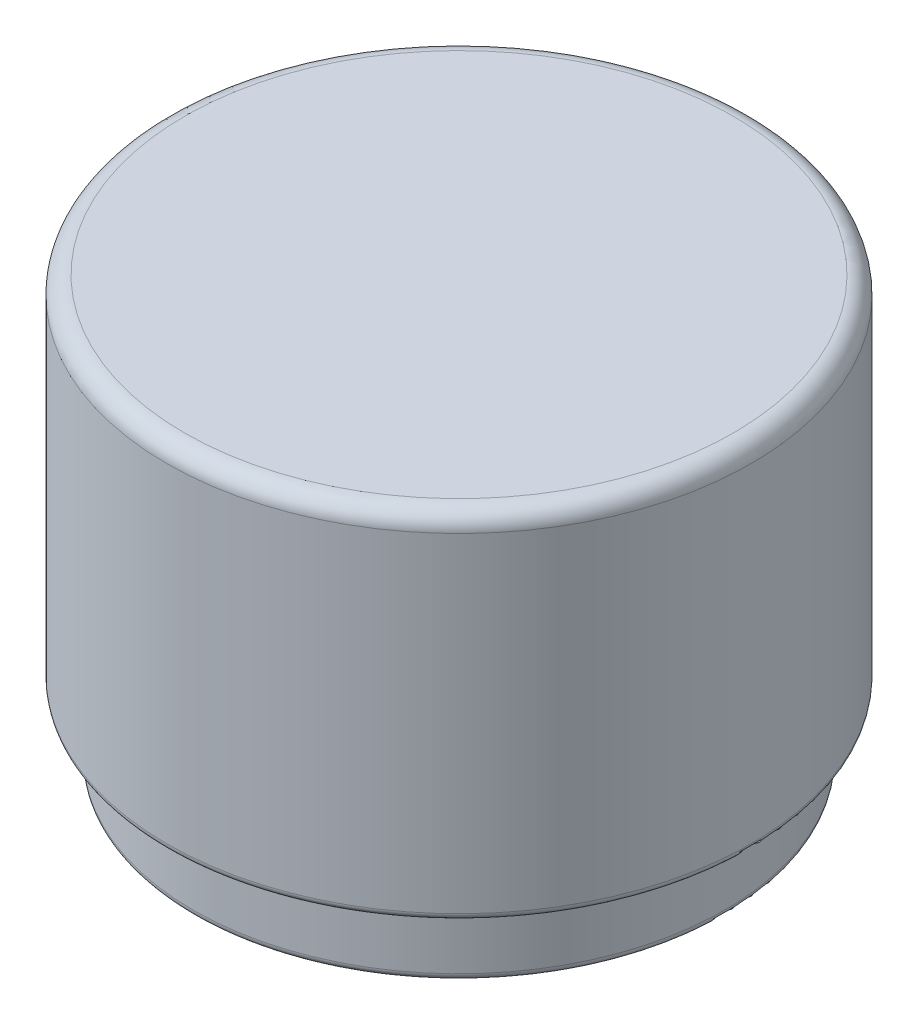
from build123d import *

# Parameters (mm, degrees)
FILLET1_R = 0.5
FILLET2_R = 0.2


with BuildPart() as part:
    # Sketch1 → Revolve1 (revolve)
    with BuildSketch(Plane(origin=(0, 0, 0), x_dir=(0, 0, -1), z_dir=(1, 0, 0))):
        Polygon((0, 0), (-8.25, 0), (-8.25, -10), (-7.5, -10), (-7.5, -12), (-7, -12), (-7, -9.5), (-7.75, -9.5), (-7.75, -0.5), (0, -0.5), align=None)
    revolve(axis=Axis((0, 0, 0), (0, -1, 0)))

    # Fillet1
    fillet1_edges = [part.edges().sort_by_distance(p)[0] for p in [
        (0, 0, -8.25),
    ]]
    fillet(fillet1_edges, radius=FILLET1_R)

    # Fillet2
    fillet2_edges = [part.edges().sort_by_distance(p)[0] for p in [
        (0, -0.5, -7.75),
        (0, -10, -8.25),
        (0, -12, -7.5),
        (0, -12, -7),
        (0, -9.5, -7),
    ]]
    fillet(fillet2_edges, radius=FILLET2_R)


solid = part.part
